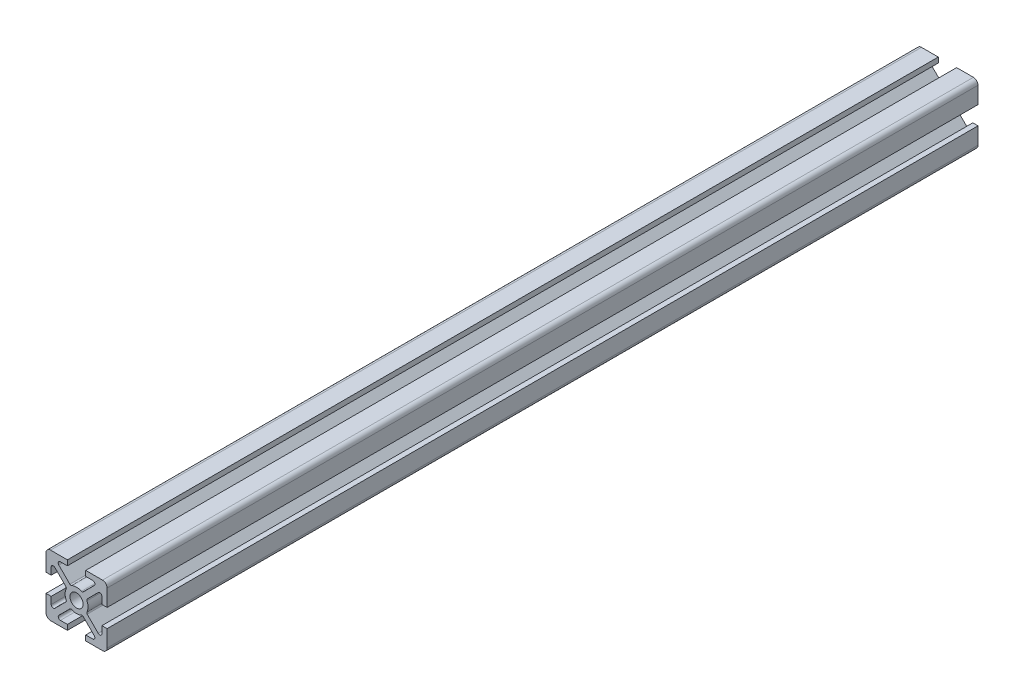
from build123d import *

# Parameters (mm, degrees)
ESQUISSE1_R        = 2.15
BOSS_EXTRU_1_DEPTH = 285


with BuildPart() as part:
    # Esquisse1 → Boss.-Extru.1 (new body)
    with BuildSketch(Plane.XY):
        with BuildLine():
            Line((-3, 10), (-8.5, 10))
            ThreePointArc((-8.5, 10), (-9.560660172, 9.560660172), (-10, 8.5))
            Line((-10, 8.5), (-10, 3))
            Line((-10, 3), (-8.300000103, 3))
            Line((-8.300000103, 3), (-8.300000103, 5.299391013))
            ThreePointArc((-8.300000103, 5.299391013), (-7.867878523, 5.946106661), (-7.105025403, 5.794365741))
            Line((-7.105025403, 5.794365741), (-3.486125569, 2.175465907))
            ThreePointArc((-3.486125569, 2.175465907), (-3.346986783, 1.907085393), (-3.38795202, 1.607569866))
            ThreePointArc((-3.38795202, 1.607569866), (-3.749999968, 1.37e-07), (-3.387952137, -1.607569618))
            ThreePointArc((-3.387952137, -1.607569618), (-3.346986918, -1.907085124), (-3.486125693, -2.175465617))
            Line((-3.486125693, -2.175465617), (-7.10502539, -5.794365497))
            ThreePointArc((-7.10502539, -5.794365497), (-7.867878514, -5.946106433), (-8.300000103, -5.299390782))
            Line((-8.300000103, -5.299390782), (-8.300000103, -3))
            Line((-8.300000103, -3), (-10, -3))
            Line((-10, -3), (-10, -8.5))
            ThreePointArc((-10, -8.5), (-9.560660172, -9.560660172), (-8.5, -10))
            Line((-8.5, -10), (-3, -10))
            Line((-3, -10), (-3, -8.29999992))
            Line((-3, -8.29999992), (-5.299390173, -8.29999992))
            ThreePointArc((-5.299390173, -8.29999992), (-5.94610582, -7.867878342), (-5.794364905, -7.105025224))
            Line((-5.794364905, -7.105025224), (-2.175465502, -3.486125765))
            ThreePointArc((-2.175465502, -3.486125765), (-1.907085014, -3.346986981), (-1.607569506, -3.38795219))
            ThreePointArc((-1.607569506, -3.38795219), (1.99e-07, -3.749999968), (1.607569866, -3.38795202))
            ThreePointArc((1.607569866, -3.38795202), (1.907085393, -3.346986783), (2.175465907, -3.486125569))
            Line((2.175465907, -3.486125569), (5.794365558, -7.10502522))
            ThreePointArc((5.794365558, -7.10502522), (5.946106478, -7.86787834), (5.29939083, -8.29999992))
            Line((5.29939083, -8.29999992), (3, -8.29999992))
            Line((3, -8.29999992), (3, -10))
            Line((3, -10), (8.499999896, -10))
            ThreePointArc((8.499999896, -10), (9.560660068, -9.560660172), (9.999999896, -8.5))
            Line((9.999999896, -8.5), (9.999999896, -3))
            Line((9.999999896, -3), (8.300000103, -3))
            Line((8.300000103, -3), (8.300000103, -5.299391569))
            ThreePointArc((8.300000103, -5.299391569), (7.867878509, -5.946107222), (7.105025381, -5.794366275))
            Line((7.105025381, -5.794366275), (3.486125475, -2.175466057))
            ThreePointArc((3.486125475, -2.175466057), (3.346986701, -1.907085538), (3.38795195, -1.607570012))
            ThreePointArc((3.38795195, -1.607570012), (3.658368452, -0.823917488), (3.749999968, 0))
            ThreePointArc((3.749999968, 0), (3.658368507, 0.823917244), (3.387952165, 1.607569559))
            ThreePointArc((3.387952165, 1.607569559), (3.346986951, 1.907085066), (3.486125731, 2.175465556))
            Line((3.486125731, 2.175465556), (7.105025399, 5.79436528))
            ThreePointArc((7.105025399, 5.79436528), (7.86787852, 5.946106205), (8.300000103, 5.299390557))
            Line((8.300000103, 5.299390557), (8.300000103, 3))
            Line((8.300000103, 3), (9.999999896, 3))
            Line((9.999999896, 3), (9.999999896, 8.5))
            ThreePointArc((9.999999896, 8.5), (9.560660068, 9.560660172), (8.499999896, 10))
            Line((8.499999896, 10), (3.499999896, 10))
            Line((3.499999896, 10), (3, 10))
            Line((3, 10), (3, 8.29999992))
            Line((3, 8.29999992), (5.299389948, 8.29999992))
            ThreePointArc((5.299389948, 8.29999992), (5.946105592, 7.867878348), (5.794364688, 7.105025232))
            Line((5.794364688, 7.105025232), (2.175465441, 3.486125803))
            ThreePointArc((2.175465441, 3.486125803), (1.907084956, 3.346987014), (1.607569447, 3.387952218))
            ThreePointArc((1.607569447, 3.387952218), (-1.51e-07, 3.749999968), (-1.60756972, 3.387952089))
            ThreePointArc((-1.60756972, 3.387952089), (-1.907085249, 3.346986865), (-2.175465757, 3.486125663))
            Line((-2.175465757, 3.486125663), (-5.794365024, 7.105025241))
            ThreePointArc((-5.794365024, 7.105025241), (-5.946105917, 7.867878353), (-5.299390275, 8.29999992))
            Line((-5.299390275, 8.29999992), (-3, 8.29999992))
            Line((-3, 8.29999992), (-3, 10))
        make_face()
        Circle(ESQUISSE1_R, mode=Mode.SUBTRACT)
    extrude(amount=BOSS_EXTRU_1_DEPTH)


solid = part.part
